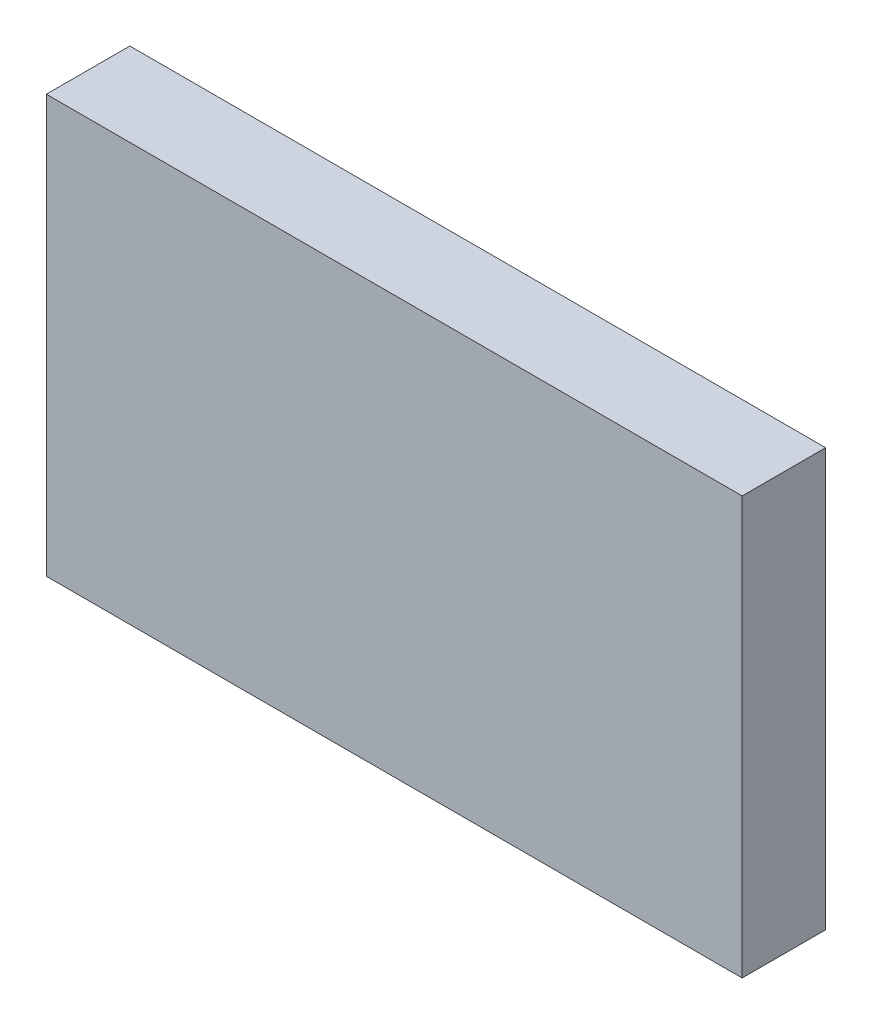
from build123d import *

# Parameters (mm, degrees)
MODEL_W             = 50
MODEL_H             = 30
BOSS_EXTRUDE1_DEPTH = 6


with BuildPart() as part:
    # Model → Boss-Extrude1 (new body)
    with BuildSketch(Plane.XY):
        with Locations((39.603507536, 22.044780119)):
            Rectangle(MODEL_W, MODEL_H)
    extrude(amount=BOSS_EXTRUDE1_DEPTH)


solid = part.part
